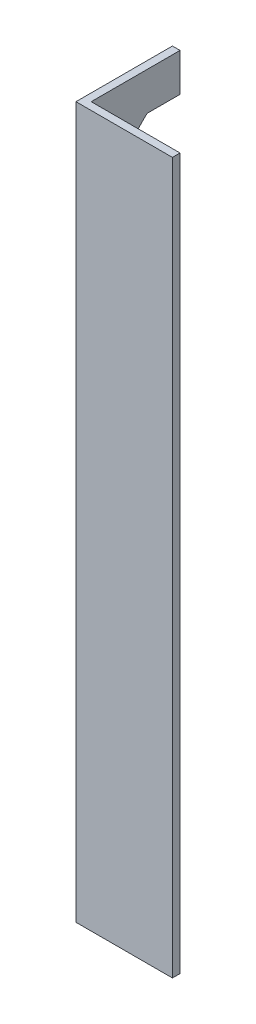
from build123d import *

# Parameters (mm, degrees)
SALIENTE_EXTRUIR1_DEPTH = 280
CROQUIS2_W              = 23
CROQUIS2_H              = 250
CORTAR_EXTRUIR1_DEPTH   = 3
CHAFL_N1_SIZE           = 10


with BuildPart() as part:
    # Croquis1 → Saliente-Extruir1 (new body)
    with BuildSketch(Plane(origin=(0, 0, 0), x_dir=(1, 0, 0), z_dir=(0, 1, 0))):
        Polygon((0, 0), (0, 38), (3, 38), (3, 3), (38, 3), (38, 0), align=None)
    extrude(amount=SALIENTE_EXTRUIR1_DEPTH)

    # Croquis2 → Cortar-Extruir1 (cut)
    with BuildSketch(Plane.ZY):
        with Locations((-26.5, 140)):
            Rectangle(CROQUIS2_W, CROQUIS2_H)
    extrude(amount=-CORTAR_EXTRUIR1_DEPTH, mode=Mode.SUBTRACT)

    # Chaflán1
    chafl_n1_edges = [part.edges().sort_by_distance(p)[0] for p in [
        (1.5, 265, -15),
        (1.5, 15, -15),
    ]]
    chamfer(chafl_n1_edges, length=CHAFL_N1_SIZE)


solid = part.part
